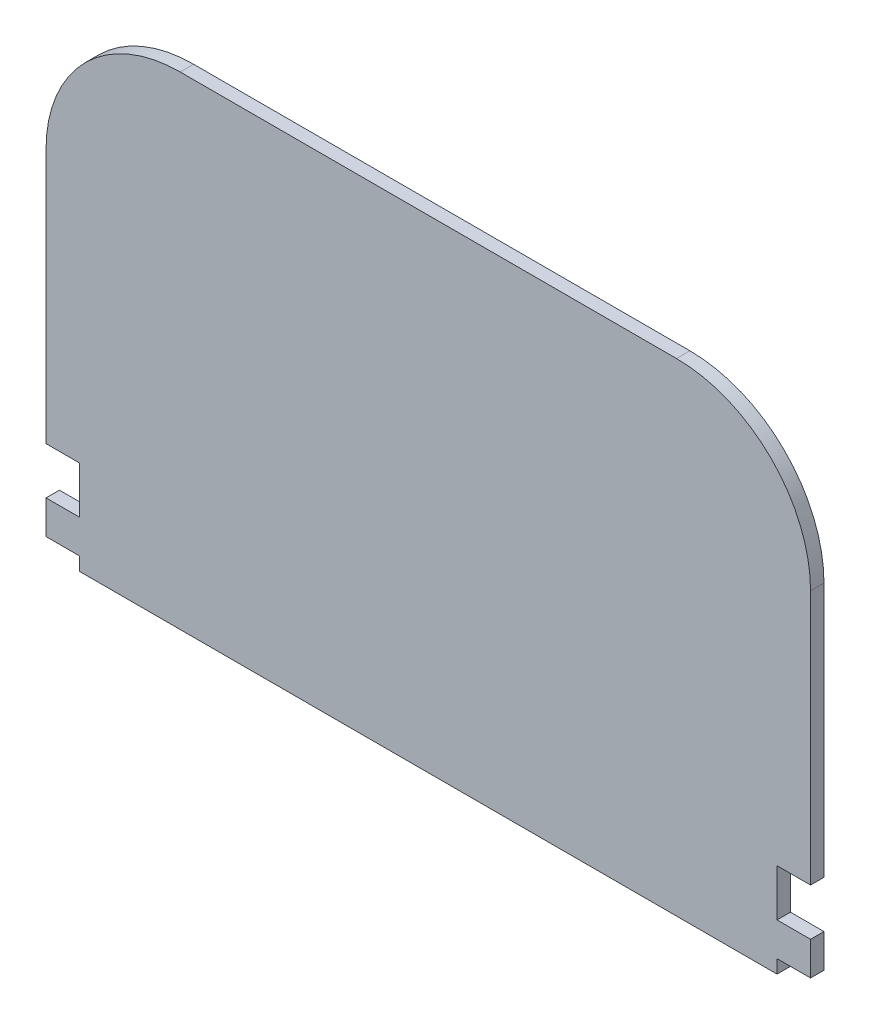
from build123d import *

# Parameters (mm, degrees)
BOSS_EXTRUDE1_DEPTH = 1


with BuildPart() as part:
    # Sketch1 → Boss-Extrude1 (new body)
    with BuildSketch(Plane.XY):
        with BuildLine():
            Line((0, 1), (2.5, 1))
            Line((2.5, 1), (2.5, 0))
            Line((2.5, 0), (54.5, 0))
            Line((54.5, 0), (54.5, 1))
            Line((54.5, 1), (57, 1))
            Line((57, 1), (57, 3.5))
            Line((57, 3.5), (54.5, 3.5))
            Line((54.5, 3.5), (54.5, 7))
            Line((54.5, 7), (57, 7))
            Line((57, 7), (57, 26))
            ThreePointArc((57, 26), (54.071067812, 33.071067812), (47, 36))
            Line((47, 36), (10, 36))
            ThreePointArc((10, 36), (2.928932188, 33.071067812), (0, 26))
            Line((0, 26), (0, 7))
            Line((0, 7), (2.5, 7))
            Line((2.5, 7), (2.5, 3.5))
            Line((2.5, 3.5), (0, 3.5))
            Line((0, 3.5), (0, 1))
        make_face()
    extrude(amount=BOSS_EXTRUDE1_DEPTH)


solid = part.part
